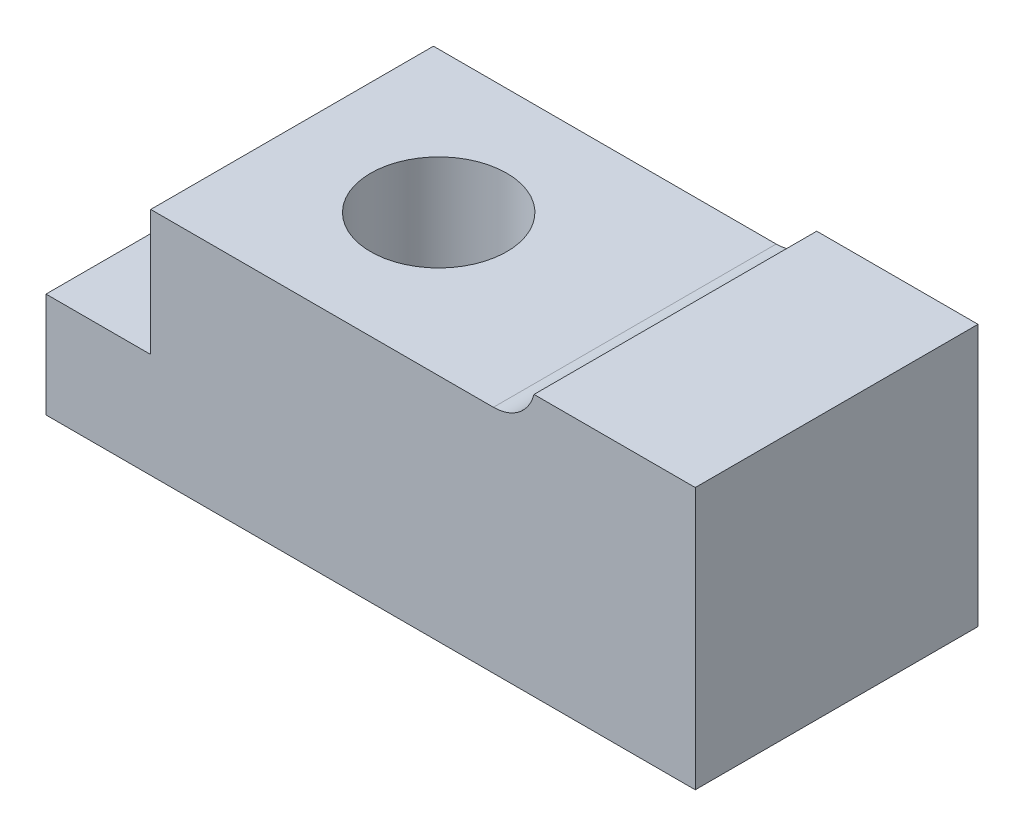
from build123d import *

# Parameters (mm, degrees)
SKETCH2_W             = 62
SKETCH2_H             = 27
BOSS_EXTRUDE1_DEPTH   = 25
CUT_EXTRUDE1_DEPTH    = 28
SKETCH4_R             = 6.5
CUT_EXTRUDE2_DEPTH    = 26
BODY_MOVE_COPY1_ANGLE = 180
BOSS_EXTRUDE2_DEPTH   = 27
SKETCH6_R             = 9.5
CUT_EXTRUDE3_DEPTH    = 12


with BuildPart() as part:
    # Sketch2 → Boss-Extrude1 (new body)
    with BuildSketch(Plane(origin=(0, 0, 0), x_dir=(1, 0, 0), z_dir=(0, 1, 0))):
        Rectangle(SKETCH2_W, SKETCH2_H)
    extrude(amount=BOSS_EXTRUDE1_DEPTH)

    # Sketch3 → Cut-Extrude1 (cut, through all)
    with BuildSketch(Plane.XY.offset(13.5)):
        Polygon((-31, 0), (23.611888282, 0), (23.611888282, 3), (-21, 3), (-21, 15), (-31, 15), align=None)
    extrude(amount=-CUT_EXTRUDE1_DEPTH, mode=Mode.SUBTRACT)

    # Sketch4 → Cut-Extrude2 (cut, through all)
    with BuildSketch(Plane(origin=(0, 25, 0), x_dir=(1, 0, 0), z_dir=(0, 1, 0))):
        with Locations((-7, 0)):
            Circle(SKETCH4_R)
    extrude(amount=-CUT_EXTRUDE2_DEPTH, mode=Mode.SUBTRACT)


with BuildPart() as part_1:
    # Body-Move/Copy1: moved
    add(part.part.rotate(Axis((0, 12.5, 0), (1, 0, 0)), BODY_MOVE_COPY1_ANGLE))

    # Sketch5 → Boss-Extrude2 (add)
    with BuildSketch(Plane.XY.offset(13.5)):
        with BuildLine():
            Line((23.611888282, 25), (15.6, 25))
            ThreePointArc((15.6, 25), (14.176506397, 22.83772234), (11.727016654, 22))
            Line((11.727016654, 22), (23.611888282, 22))
            Line((23.611888282, 22), (23.611888282, 25))
        make_face()
    extrude(amount=-BOSS_EXTRUDE2_DEPTH)

    # Sketch6 → Cut-Extrude3 (cut)
    with BuildSketch(Plane.XZ):
        with Locations((-7, 0)):
            Circle(SKETCH6_R)
    extrude(amount=-CUT_EXTRUDE3_DEPTH, mode=Mode.SUBTRACT)


solid = part_1.part
